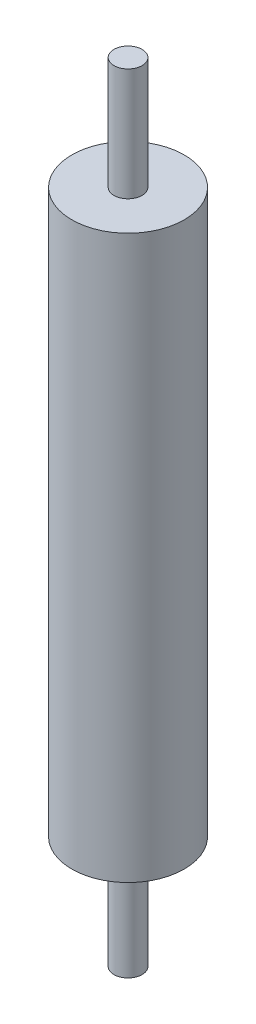
from build123d import *


with BuildPart() as part:
    # Sketch1 → Revolve1 (revolve)
    with BuildSketch(Plane.XY):
        Polygon((-10, -50), (-10, 50), (-2.5, 50), (-2.5, 70), (0, 70), (0, -70), (-2.5, -70), (-2.5, -50), align=None)
    revolve(axis=Axis((0, -70, 0), (0, 1, 0)))


solid = part.part
